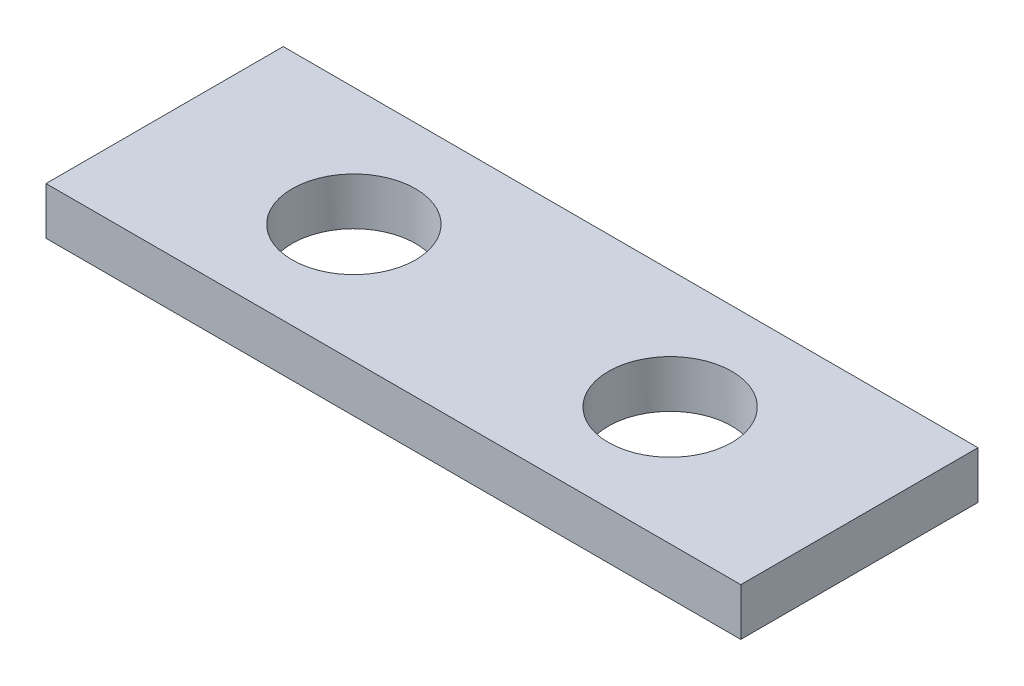
from build123d import *

# Parameters (mm, degrees)
SKETCH1_W           = 43.93
SKETCH1_H           = 15
BOSS_EXTRUDE1_DEPTH = 3
CUT_EXTRUDE1_START  = -4
SKETCH2_R           = 3.9
CUT_EXTRUDE1_DEPTH  = 5


with BuildPart() as part:
    # Sketch1 → Boss-Extrude1 (new body)
    with BuildSketch(Plane(origin=(0, 0, 0), x_dir=(1, 0, 0), z_dir=(0, 1, 0))):
        Rectangle(SKETCH1_W, SKETCH1_H)
    extrude(amount=BOSS_EXTRUDE1_DEPTH)

    # Sketch2 → Cut-Extrude1 (cut)
    with BuildSketch(Plane(origin=(0, 3, 0), x_dir=(1, 0, 0), z_dir=(0, 1, 0)).offset(CUT_EXTRUDE1_START)):
        with Locations((-10, 0)):
            Circle(SKETCH2_R)
    cut_extrude1 = extrude(amount=CUT_EXTRUDE1_DEPTH, mode=Mode.SUBTRACT)

    # Mirror1: Cut-Extrude1 across plane
    add(cut_extrude1.mirror(Plane(origin=(0, 0, 0), x_dir=(0, 0, 1), z_dir=(1, 0, 0))), mode=Mode.SUBTRACT)


solid = part.part
